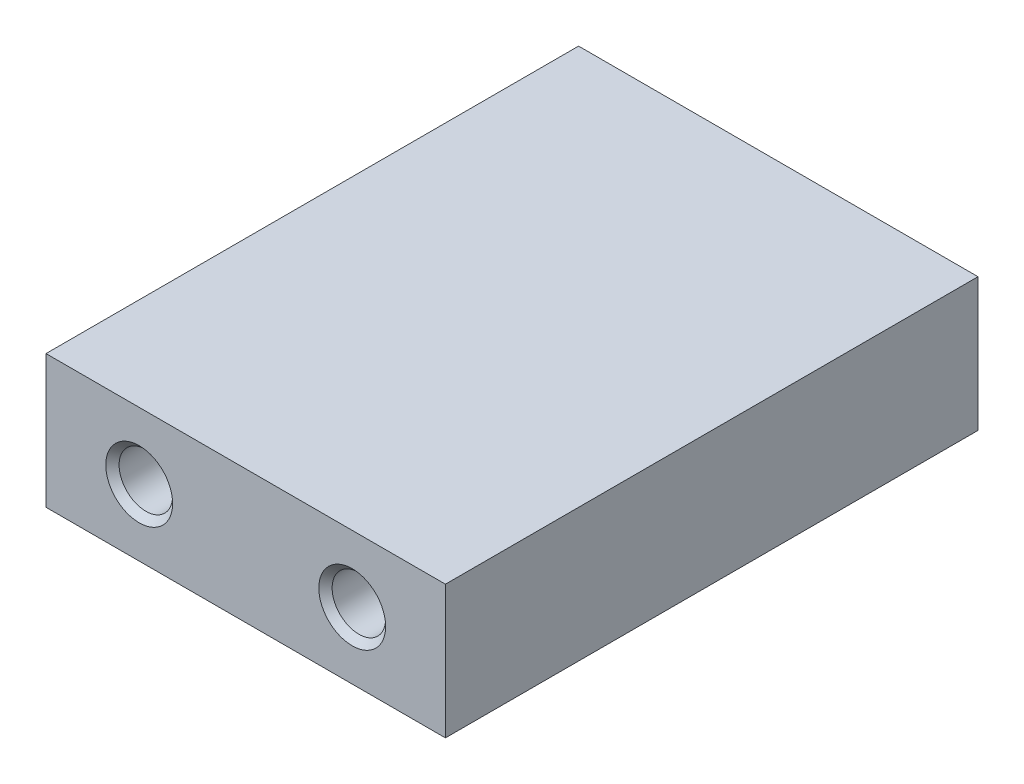
from build123d import *

# Parameters (mm, degrees)
SKETCH1_W                        = 38.1
SKETCH1_H                        = 12.7
BOSS_EXTRUDE1_DEPTH              = 50.8
F_1_4_20_TAPPED_HOLE1_AT_2_COUNT = 2
F_1_4_20_TAPPED_HOLE1_AT_2_PITCH = 20.32
F_1_8_0_125_DIAMETER_HOLE1_D     = 3.175
F_1_8_0_125_DIAMETER_HOLE1_DEPTH = 5.08
F_1_8_0_125_DIAMETER_HOLE1_TIP   = 0.953866233


with BuildPart() as part:
    # Sketch1 → Boss-Extrude1 (new body)
    with BuildSketch(Plane.XY):
        Rectangle(SKETCH1_W, SKETCH1_H)
    extrude(amount=-BOSS_EXTRUDE1_DEPTH)

    # Sketch4 → 1/4-20 Tapped Hole1 (revolve, cut)
    with BuildSketch(Plane(origin=(-10.16, 0, 0), x_dir=(0, -1, 0), z_dir=(1, 0, 0))):
        Polygon((0, 0), (0, 14.233816902), (2.5527, 12.7), (2.5527, 0.635), (3.1877, 0), align=None)
    f_1_4_20_tapped_hole1 = revolve(axis=Axis((-10.16, 0, 6.35), (0, 0, -1)), mode=Mode.SUBTRACT)

    # 1/4-20 Tapped Hole1 at 2: 1/4-20 Tapped Hole1 ×2
    with Locations(*[(i * F_1_4_20_TAPPED_HOLE1_AT_2_PITCH, 0, 0) for i in range(1, F_1_4_20_TAPPED_HOLE1_AT_2_COUNT)]):
        add(f_1_4_20_tapped_hole1, mode=Mode.SUBTRACT)

    # Mirror1: 1/4-20 Tapped Hole1 across plane
    add(f_1_4_20_tapped_hole1.mirror(Plane.XY.offset(-25.4)), mode=Mode.SUBTRACT)

    # Mirror1 copy 1 sketch → Mirror1 copy 1 (revolve, cut)
    with BuildSketch(Plane(origin=(10.16, 0, -50.8), x_dir=(0, -1, 0), z_dir=(1, 0, 0))):
        Polygon((0, 0), (0, -14.233816902), (2.5527, -12.7), (2.5527, -0.635), (3.1877, 0), align=None)
    revolve(axis=Axis((10.16, 0, -57.15), (0, 0, -1)), mode=Mode.SUBTRACT)

    # 1/8 (0.125) Diameter Hole1
    with Locations(Plane.ZY.offset(19.05)):
        with Locations((-34.29, 0), (-16.51, 0)):
            Hole(F_1_8_0_125_DIAMETER_HOLE1_D / 2, depth=F_1_8_0_125_DIAMETER_HOLE1_DEPTH)
            with Locations((0, 0, -(F_1_8_0_125_DIAMETER_HOLE1_DEPTH + F_1_8_0_125_DIAMETER_HOLE1_TIP / 2))):  # 118° drill point
                Cone(0, F_1_8_0_125_DIAMETER_HOLE1_D / 2, F_1_8_0_125_DIAMETER_HOLE1_TIP, mode=Mode.SUBTRACT)


solid = part.part
